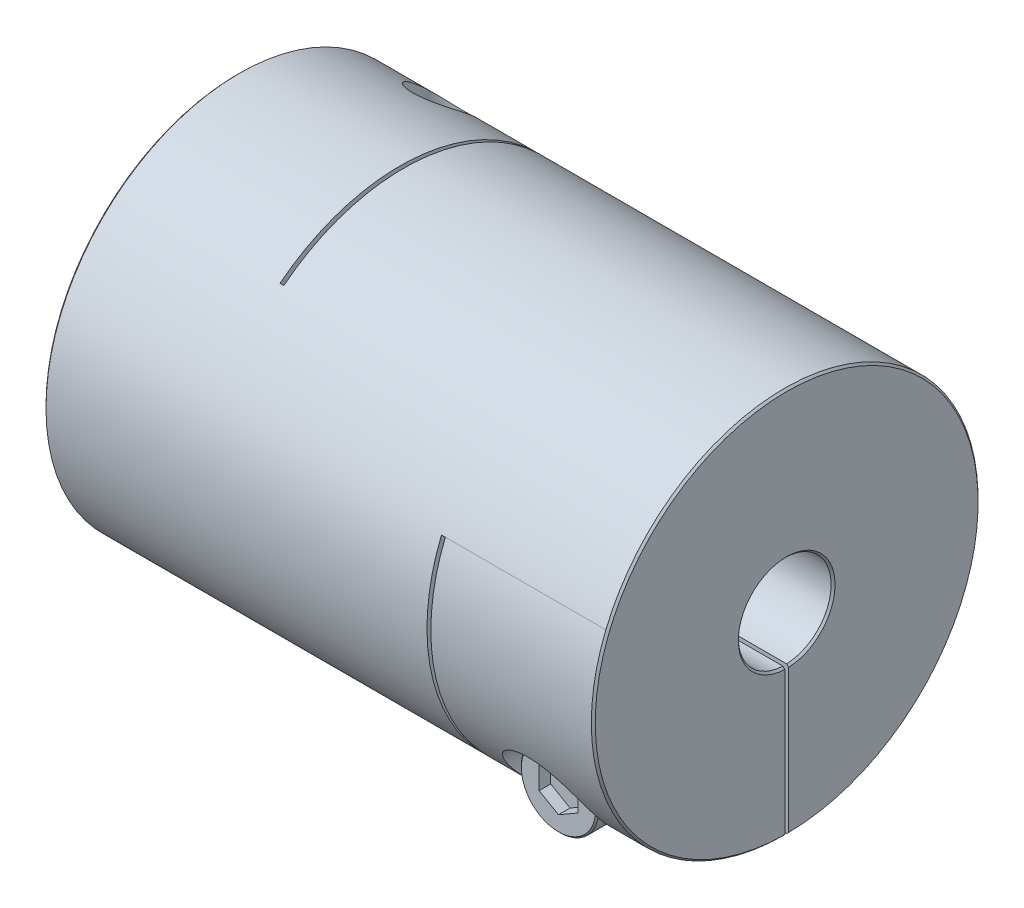
from build123d import *

# Parameters (mm, degrees)
SKETCH1_R                      = 25
BOSS_EXTRUDE1_DEPTH            = 35.5
SKETCH2_R                      = 6
CUT_EXTRUDE1_DEPTH             = 72
CHAMFER1_SIZE                  = 0.254
SKETCH4_W                      = 0.5
SKETCH4_H                      = 40.5
CUT_EXTRUDE2_DEPTH             = 51
SKETCH7_W                      = 0.5
SKETCH7_H                      = 34.5
CUT_EXTRUDE3_DEPTH             = 51
SKETCH8_W                      = 21
SKETCH8_H                      = 25
CUT_EXTRUDE5_DEPTH             = 0.25
SKETCH13_W                     = 21
SKETCH13_H                     = 25
CUT_EXTRUDE6_DEPTH             = 0.25
CBORE_FOR_M6_SHCS1_D           = 6.6
CBORE_FOR_M6_SHCS1_CBORE_D     = 11
CBORE_FOR_M6_SHCS1_CBORE_DEPTH = 12
CBORE_FOR_M6_SHCS2_D           = 6.6
CBORE_FOR_M6_SHCS2_CBORE_D     = 11
CBORE_FOR_M6_SHCS2_CBORE_DEPTH = 12
SKETCH16_R                     = 5
BOSS_EXTRUDE2_DEPTH            = 6
SKETCH17_R                     = 1
BOSS_EXTRUDE3_DEPTH            = 6.5
CHAMFER2_SIZE                  = 0.2
CUT_EXTRUDE7_DEPTH             = 1.5
CIRPATTERN1_COUNT              = 2
CIRPATTERN1_ANGLE              = 90


with BuildPart() as part:
    # Sketch1 → Boss-Extrude1 (new body, symmetric)
    with BuildSketch(Plane(origin=(0, 0, 0), x_dir=(0, 0, -1), z_dir=(1, 0, 0))):
        Circle(SKETCH1_R)
    extrude(amount=BOSS_EXTRUDE1_DEPTH, both=True)

    # Sketch2 → Cut-Extrude1 (cut, through all)
    with BuildSketch(Plane(origin=(35.5, 0, 0), x_dir=(0, 0, -1), z_dir=(1, 0, 0))):
        Circle(SKETCH2_R)
    extrude(amount=-CUT_EXTRUDE1_DEPTH, mode=Mode.SUBTRACT)

    # Chamfer1
    chamfer1_edges = [part.edges().sort_by_distance(p)[0] for p in [
        (-35.5, 0, 25),
        (35.5, 0, 25),
        (-35.5, 0, 6),
        (35.5, 0, 6),
    ]]
    chamfer(chamfer1_edges, length=CHAMFER1_SIZE)

    # Sketch4 → Cut-Extrude2 (cut, through all)
    with BuildSketch(Plane.XZ.offset(25)):
        with Locations((-14.25, -4.75)):
            Rectangle(SKETCH4_W, SKETCH4_H)
    extrude(amount=-CUT_EXTRUDE2_DEPTH, mode=Mode.SUBTRACT)

    # Sketch7 → Cut-Extrude3 (cut, through all)
    with BuildSketch(Plane(origin=(0, 0, -25), x_dir=(-1, 0, 0), z_dir=(0, 0, -1))):
        with Locations((-14.25, -7.75)):
            Rectangle(SKETCH7_W, SKETCH7_H)
    extrude(amount=-CUT_EXTRUDE3_DEPTH, mode=Mode.SUBTRACT)

    # Sketch8 → Cut-Extrude5 (cut, symmetric)
    with BuildSketch(Plane(origin=(0, 0, 0), x_dir=(1, 0, 0), z_dir=(0, 1, 0))):
        with Locations((-25, 12.5)):
            Rectangle(SKETCH8_W, SKETCH8_H)
    extrude(amount=CUT_EXTRUDE5_DEPTH, both=True, mode=Mode.SUBTRACT)

    # Sketch13 → Cut-Extrude6 (cut, symmetric)
    with BuildSketch(Plane.XY):
        with Locations((25, -12.5)):
            Rectangle(SKETCH13_W, SKETCH13_H)
    extrude(amount=CUT_EXTRUDE6_DEPTH, both=True, mode=Mode.SUBTRACT)

    # CBORE for M6 SHCS1 (through all)
    with Locations(Plane.XZ.offset(25)):
        with Locations((-25, -15.496769686)):
            CounterBoreHole(CBORE_FOR_M6_SHCS1_D / 2, CBORE_FOR_M6_SHCS1_CBORE_D / 2, CBORE_FOR_M6_SHCS1_CBORE_DEPTH)

    # CBORE for M6 SHCS2 (through all)
    with Locations(Plane.XY.offset(25)):
        with Locations((25, -15.496769686)):
            CounterBoreHole(CBORE_FOR_M6_SHCS2_D / 2, CBORE_FOR_M6_SHCS2_CBORE_D / 2, CBORE_FOR_M6_SHCS2_CBORE_DEPTH)


with BuildPart() as body_2:
    # Sketch16 → Boss-Extrude2 (new body)
    with BuildSketch(Plane.XY.offset(13)):
        with Locations((25, -15.496769686)):
            Circle(SKETCH16_R)
    extrude(amount=BOSS_EXTRUDE2_DEPTH)

    # Sketch17 → Boss-Extrude3 (add)
    with BuildSketch(Plane(origin=(0, 0, 13), x_dir=(-1, 0, 0), z_dir=(0, 0, -1))):
        with Locations(Location((-25, -15.496769686, 0), (0, 0, 180))):  # turned: the seam where the file's is
            Circle(SKETCH17_R)
    extrude(amount=BOSS_EXTRUDE3_DEPTH)

    # Chamfer2
    chamfer2_edges = [body_2.edges().sort_by_distance(p)[0] for p in [
        (20, -15.496769686, 13),
        (20, -15.496769686, 19),
        (24, -15.496769686, 6.5),
    ]]
    chamfer(chamfer2_edges, length=CHAMFER2_SIZE)

    # Sketch18 → Cut-Extrude7 (cut)
    with BuildSketch(Plane.XY.offset(19)):
        Polygon((25, -18.383521032), (27.5, -16.940145359), (27.5, -14.053394013), (25, -12.61001834), (22.5, -14.053394013), (22.5, -16.940145359), align=None)
    extrude(amount=-CUT_EXTRUDE7_DEPTH, mode=Mode.SUBTRACT)


with BuildPart() as body_3:
    # Mirror1: mirrored copy
    add(body_2.part.mirror(Plane(origin=(0, 0, 0), x_dir=(0, 0, 1), z_dir=(1, 0, 0))))


with BuildPart() as cirpattern1_1:
    # CirPattern1: pattern copy
    add(body_3.part.rotate(Axis((0, 0, 0), (1, 0, 0)), 1 * CIRPATTERN1_ANGLE / (CIRPATTERN1_COUNT - 1)))


solid = Compound([part.part, body_2.part, cirpattern1_1.part])
